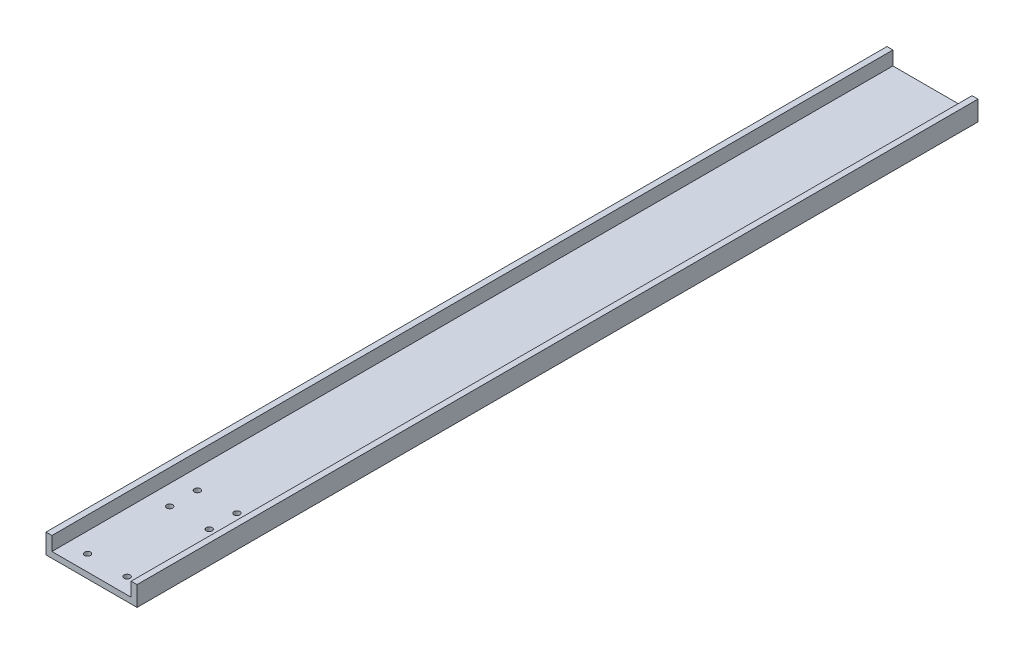
from build123d import *

# Parameters (mm, degrees)
BOSS_EXTRUDE1_DEPTH       = 425
F_3_0MM_DOWEL_HOLE1_D     = 3
F_3_0MM_DOWEL_HOLE1_DEPTH = 15
F_3_0MM_DOWEL_HOLE1_TIP   = 0.901290929
F_3_0MM_DOWEL_HOLE2_D     = 3
F_3_0MM_DOWEL_HOLE2_DEPTH = 15
F_3_0MM_DOWEL_HOLE2_TIP   = 0.901290929


with BuildPart() as part:
    # Sketch1 → Boss-Extrude1 (new body)
    with BuildSketch(Plane.XY):
        Polygon((0, 0), (0, 7), (-3, 7), (-3, -3), (43, -3), (43, 7), (40, 7), (40, 0), align=None)
    extrude(amount=BOSS_EXTRUDE1_DEPTH)

    # Ø3.0mm Dowel Hole1
    with Locations(Plane(origin=(0, 0, 0), x_dir=(1, 0, 0), z_dir=(0, 1, 0))):
        with Locations((10, -375.5), (30, -375.5), (30, -361.5), (10, -361.5)):
            Hole(F_3_0MM_DOWEL_HOLE1_D / 2, depth=F_3_0MM_DOWEL_HOLE1_DEPTH)
            with Locations((0, 0, -(F_3_0MM_DOWEL_HOLE1_DEPTH + F_3_0MM_DOWEL_HOLE1_TIP / 2))):  # 118° drill point
                Cone(0, F_3_0MM_DOWEL_HOLE1_D / 2, F_3_0MM_DOWEL_HOLE1_TIP, mode=Mode.SUBTRACT)

    # Ø3.0mm Dowel Hole2
    with Locations(Plane(origin=(0, -3, 0), x_dir=(-1, 0, 0), z_dir=(0, -1, 0))):
        with Locations((-30, -417), (-10, -417)):
            Hole(F_3_0MM_DOWEL_HOLE2_D / 2, depth=F_3_0MM_DOWEL_HOLE2_DEPTH)
            with Locations((0, 0, -(F_3_0MM_DOWEL_HOLE2_DEPTH + F_3_0MM_DOWEL_HOLE2_TIP / 2))):  # 118° drill point
                Cone(0, F_3_0MM_DOWEL_HOLE2_D / 2, F_3_0MM_DOWEL_HOLE2_TIP, mode=Mode.SUBTRACT)


solid = part.part
